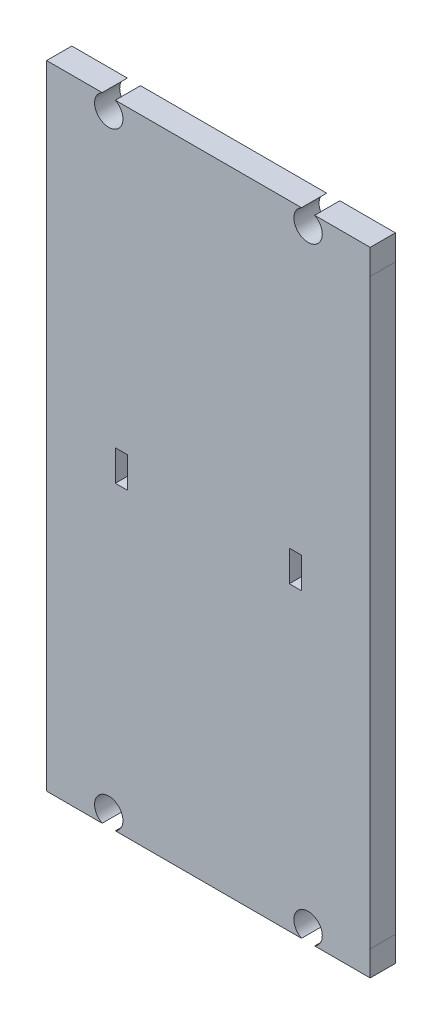
from build123d import *

# Parameters (mm, degrees)
BOSS_EXTRUDE1_DEPTH = 3.1115


with BuildPart() as part:
    # Sketch1 → Boss-Extrude1 (new body)
    with BuildSketch(Plane.XY):
        with BuildLine():
            Line((-11.346747426, -39.119290122), (11.669367426, -39.119721696))
            ThreePointArc((11.669367426, -39.119721696), (12.481628508, -35.808987017), (13.293765431, -39.119752155))
            Line((13.293765431, -39.119752155), (20.161810992, -39.119880937))
            Line((20.161810992, -39.119880937), (20.161869308, -36.009880938))
            Line((20.161869308, -36.009880938), (20.162213663, 35.990119062))
            Line((20.162213663, 35.990119062), (20.162213663, 39.100119058))
            Line((20.162213663, 39.100119058), (13.352237556, 39.100119058))
            Line((13.352237556, 39.100119058), (13.294498779, 39.100119058))
            ThreePointArc((13.294498779, 39.100119058), (12.482299776, 35.789369149), (11.670100774, 39.100119058))
            Line((11.670100774, 39.100119058), (-11.346014082, 39.100119058))
            ThreePointArc((-11.346014082, 39.100119058), (-12.158213085, 35.789369149), (-12.970412087, 39.100119058))
            Line((-12.970412087, 39.100119058), (-19.837839981, 39.100119058))
            Line((-19.837839981, 39.100119058), (-19.837939244, -36.009130904))
            Line((-19.837939244, -36.009130904), (-19.837956649, -39.119130904))
            Line((-19.837956649, -39.119130904), (-12.97114543, -39.119259663))
            ThreePointArc((-12.97114543, -39.119259663), (-12.158884348, -35.808524984), (-11.346747426, -39.119290122))
        make_face()
        Polygon((10.162043346, -0.008380505), (10.162043346, -1.913380505), (11.672043346, -1.913380505), (11.672043346, 1.896619495), (10.162043346, 1.896619495), align=None, mode=Mode.SUBTRACT)
        Polygon((-9.837956654, 1.896619495), (-9.837956654, -0.008380505), (-9.837956654, -1.913380505), (-11.347956654, -1.913380505), (-11.347956654, 1.896619495), align=None, mode=Mode.SUBTRACT)
    extrude(amount=BOSS_EXTRUDE1_DEPTH)


solid = part.part
